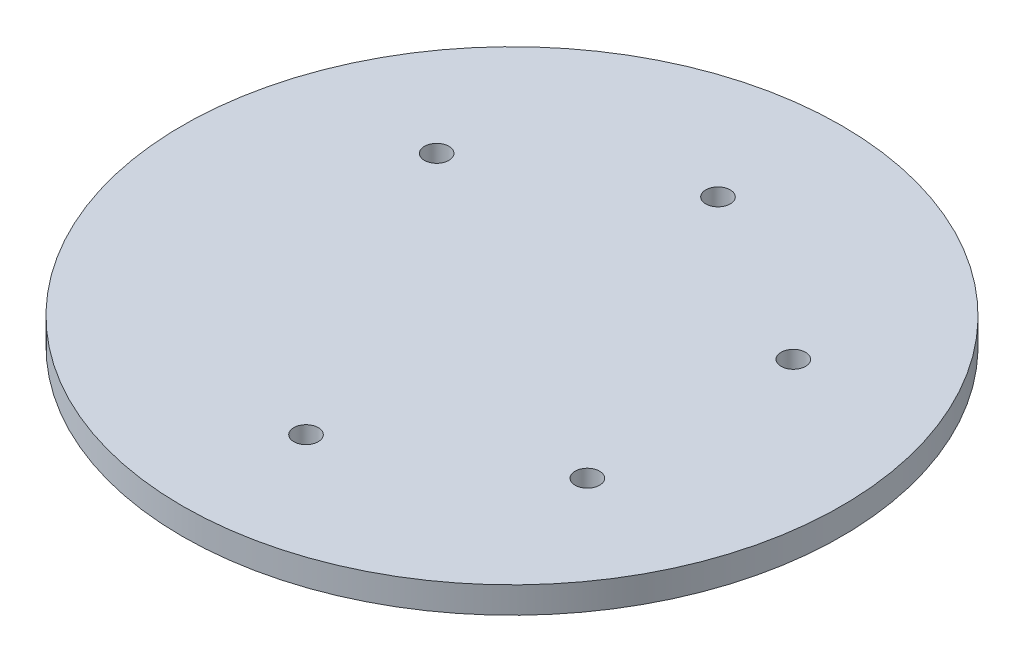
from build123d import *

# Parameters (mm, degrees)
SKETCH1_R           = 20
BOSS_EXTRUDE1_DEPTH = 1.6
SKETCH2_R           = 0.743
CUT_EXTRUDE2_DEPTH  = 1.6


with BuildPart() as part:
    # Sketch1 → Boss-Extrude1 (new body)
    with BuildSketch(Plane(origin=(0, 0, 0), x_dir=(1, 0, 0), z_dir=(0, 1, 0))):
        Circle(SKETCH1_R)
    extrude(amount=-BOSS_EXTRUDE1_DEPTH)

    # Sketch2 → Cut-Extrude2 (cut)
    with BuildSketch(Plane.XZ.offset(1.6)):
        with Locations((-0.00171005, 12.498814086)):
            Circle(SKETCH2_R)
        with Locations((10.823435491, 6.25088799)):
            Circle(SKETCH2_R)
        with Locations((10.825145541, -6.247926096)):
            Circle(SKETCH2_R)
        with Locations((0.00171005, -12.498814086)):
            Circle(SKETCH2_R)
        with Locations((-10.823435491, -6.25088799)):
            Circle(SKETCH2_R)
    extrude(amount=-CUT_EXTRUDE2_DEPTH, mode=Mode.SUBTRACT)


solid = part.part
